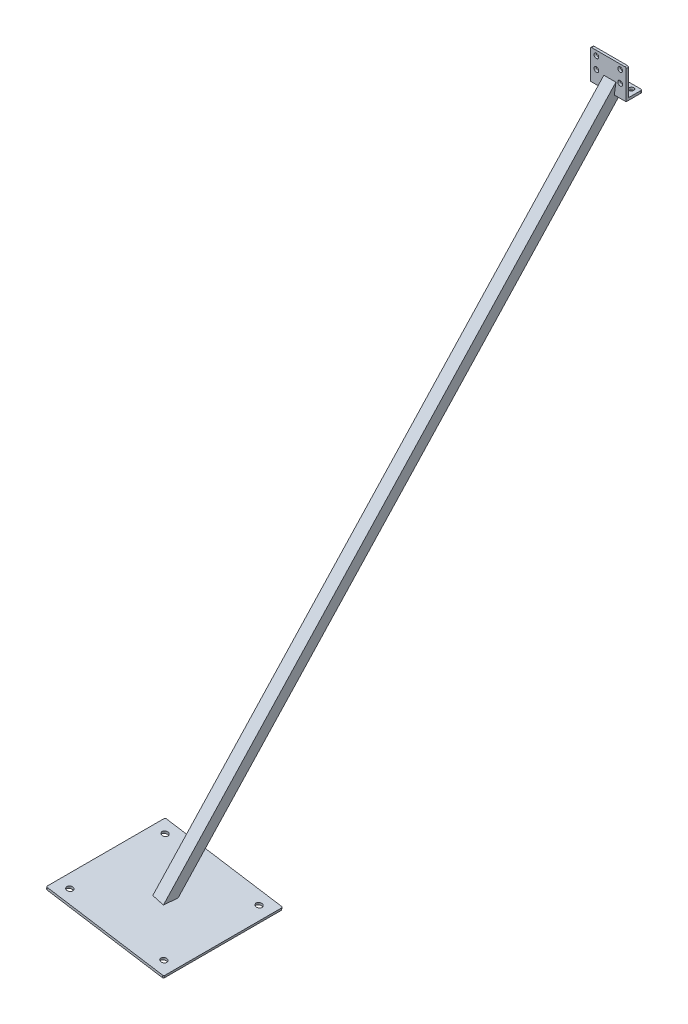
from build123d import *

# Parameters (mm, degrees)
BOSS_EXTRUDE1_DEPTH      = 60
SKETCH3_W                = 20
SKETCH3_H                = 20
SKETCH3_W_2              = 18
SKETCH3_H_2              = 18
BOSS_EXTRUDE2_DEPTH      = 2000
BOSS_EXTRUDE2_DEPTH_BACK = 20
CUT_EXTRUDE1_DEPTH       = 60
SKETCH6_W                = 200
SKETCH6_H                = 200
BOSS_EXTRUDE3_DEPTH      = 4
SKETCH7_W                = 155.890708873
SKETCH7_H                = 491.291930993
CUT_EXTRUDE2_DEPTH       = 1000
CUT_EXTRUDE3_REACH       = 29
SKETCH8_R                = 3.999999996
CUT_EXTRUDE4_REACH       = 52
SKETCH9_R                = 4.000000003
CUT_EXTRUDE5_REACH       = 1055.099
SKETCH10_R               = 5
FILLET1_R                = 2
FILLET2_R                = 2


with BuildPart() as part:
    # Sketch1 → Boss-Extrude1 (new body)
    with BuildSketch(Plane(origin=(0, 0, 0), x_dir=(0, 0, -1), z_dir=(1, 0, 0))):
        Polygon((0, 0), (0, 50), (4, 50), (4, 4), (27, 4), (27, 0), align=None)
    extrude(amount=BOSS_EXTRUDE1_DEPTH)

    # Sketch3 → Boss-Extrude2 (add, two sides)
    with BuildSketch(Plane(origin=(0.734152256, 4.01424851, -2.317627458), x_dir=(0, -0.5, -0.866025404), z_dir=(-0.156434465, -0.855363194, 0.49384417))) as boss_extrude2_sk:
        with Locations((0, 29.630650218)):
            Rectangle(SKETCH3_W, SKETCH3_H)
        with Locations((0, 29.630650218)):
            Rectangle(SKETCH3_W_2, SKETCH3_H_2, mode=Mode.SUBTRACT)
    extrude(amount=BOSS_EXTRUDE2_DEPTH)
    extrude(boss_extrude2_sk.sketch, amount=-BOSS_EXTRUDE2_DEPTH_BACK)

    # Sketch4 → Cut-Extrude1 (cut)
    with BuildSketch(Plane.ZY):
        Polygon((-4, 4), (-4, 34.425897354), (-31.384039134, 4), align=None)
    extrude(amount=-CUT_EXTRUDE1_DEPTH, mode=Mode.SUBTRACT)

    # Sketch6 → Boss-Extrude3 (add)
    with BuildSketch(Plane(origin=(-155.547262091, -982.086761679, 2e-09), x_dir=(0.987688341, -0.156434465, 0), z_dir=(0.156434465, 0.987688341, 0))):
        with Locations((5.477031179, -566.441418586)):
            Rectangle(SKETCH6_W, SKETCH6_H)
    extrude(amount=BOSS_EXTRUDE3_DEPTH)

    # Sketch7 → Cut-Extrude2 (cut)
    with BuildSketch(Plane(origin=(-155.547262091, -982.086761679, 2e-09), x_dir=(0.987688341, -0.156434465, 0), z_dir=(-0.156434465, -0.987688341, 0))):
        with Locations((-7.001123273, 786.089826429)):
            Rectangle(SKETCH7_W, SKETCH7_H)
    extrude(amount=CUT_EXTRUDE2_DEPTH, mode=Mode.SUBTRACT)

    # Sketch8 → Cut-Extrude3 (cut, up to next)
    with BuildSketch(Plane.XY, mode=Mode.PRIVATE) as cut_extrude3_sk1:
        with Locations((10, 22)):
            Circle(SKETCH8_R)
    cut_extrude3_tool1 = extrude(cut_extrude3_sk1.sketch, amount=-CUT_EXTRUDE3_REACH, mode=Mode.PRIVATE) & part.part
    add(cut_extrude3_tool1.solids().sort_by_distance((10, 22, 0))[0], mode=Mode.SUBTRACT)
    # Sketch8 → Cut-Extrude3 (cut, up to next)
    with BuildSketch(Plane.XY, mode=Mode.PRIVATE) as cut_extrude3_sk2:
        with Locations((50, 22)):
            Circle(SKETCH8_R)
    cut_extrude3_tool2 = extrude(cut_extrude3_sk2.sketch, amount=-CUT_EXTRUDE3_REACH, mode=Mode.PRIVATE) & part.part
    add(cut_extrude3_tool2.solids().sort_by_distance((50, 22, 0))[0], mode=Mode.SUBTRACT)
    # Sketch8 → Cut-Extrude3 (cut, up to next)
    with BuildSketch(Plane.XY, mode=Mode.PRIVATE) as cut_extrude3_sk3:
        with Locations((50, 42)):
            Circle(SKETCH8_R)
    cut_extrude3_tool3 = extrude(cut_extrude3_sk3.sketch, amount=-CUT_EXTRUDE3_REACH, mode=Mode.PRIVATE) & part.part
    add(cut_extrude3_tool3.solids().sort_by_distance((50, 42, 0))[0], mode=Mode.SUBTRACT)
    # Sketch8 → Cut-Extrude3 (cut, up to next)
    with BuildSketch(Plane.XY, mode=Mode.PRIVATE) as cut_extrude3_sk4:
        with Locations((10, 42)):
            Circle(SKETCH8_R)
    cut_extrude3_tool4 = extrude(cut_extrude3_sk4.sketch, amount=-CUT_EXTRUDE3_REACH, mode=Mode.PRIVATE) & part.part
    add(cut_extrude3_tool4.solids().sort_by_distance((10, 42, 0))[0], mode=Mode.SUBTRACT)

    # Sketch9 → Cut-Extrude4 (cut, up to next)
    with BuildSketch(Plane.XZ, mode=Mode.PRIVATE) as cut_extrude4_sk1:
        with Locations((50, -19)):
            Circle(SKETCH9_R)
    cut_extrude4_tool1 = extrude(cut_extrude4_sk1.sketch, amount=-CUT_EXTRUDE4_REACH, mode=Mode.PRIVATE) & part.part
    add(cut_extrude4_tool1.solids().sort_by_distance((50, 0, -19))[0], mode=Mode.SUBTRACT)
    # Sketch9 → Cut-Extrude4 (cut, up to next)
    with BuildSketch(Plane.XZ, mode=Mode.PRIVATE) as cut_extrude4_sk2:
        with Locations((10, -19)):
            Circle(SKETCH9_R)
    cut_extrude4_tool2 = extrude(cut_extrude4_sk2.sketch, amount=-CUT_EXTRUDE4_REACH, mode=Mode.PRIVATE) & part.part
    add(cut_extrude4_tool2.solids().sort_by_distance((10, 0, -19))[0], mode=Mode.SUBTRACT)

    # Sketch10 → Cut-Extrude5 (cut, up to next)
    with BuildSketch(Plane(origin=(-155.547262091, -982.086761679, 2e-09), x_dir=(0.987688341, -0.156434465, 0), z_dir=(-0.156434465, -0.987688341, 0)), mode=Mode.PRIVATE) as cut_extrude5_sk1:
        with Locations((-74.522968944, 646.441418561)):
            Circle(SKETCH10_R)
    cut_extrude5_tool1 = extrude(cut_extrude5_sk1.sketch, amount=-CUT_EXTRUDE5_REACH, mode=Mode.PRIVATE) & part.part
    add(cut_extrude5_tool1.solids().sort_by_distance((-229.152729, -970.428801, 646.441419))[0], mode=Mode.SUBTRACT)
    # Sketch10 → Cut-Extrude5 (cut, up to next)
    with BuildSketch(Plane(origin=(-155.547262091, -982.086761679, 2e-09), x_dir=(0.987688341, -0.156434465, 0), z_dir=(-0.156434465, -0.987688341, 0)), mode=Mode.PRIVATE) as cut_extrude5_sk2:
        with Locations((85.477031056, 646.441418561)):
            Circle(SKETCH10_R)
    cut_extrude5_tool2 = extrude(cut_extrude5_sk2.sketch, amount=-CUT_EXTRUDE5_REACH, mode=Mode.PRIVATE) & part.part
    add(cut_extrude5_tool2.solids().sort_by_distance((-71.122595, -995.458315, 646.441419))[0], mode=Mode.SUBTRACT)
    # Sketch10 → Cut-Extrude5 (cut, up to next)
    with BuildSketch(Plane(origin=(-155.547262091, -982.086761679, 2e-09), x_dir=(0.987688341, -0.156434465, 0), z_dir=(-0.156434465, -0.987688341, 0)), mode=Mode.PRIVATE) as cut_extrude5_sk3:
        with Locations((85.477031056, 486.441418561)):
            Circle(SKETCH10_R)
    cut_extrude5_tool3 = extrude(cut_extrude5_sk3.sketch, amount=-CUT_EXTRUDE5_REACH, mode=Mode.PRIVATE) & part.part
    add(cut_extrude5_tool3.solids().sort_by_distance((-71.122595, -995.458315, 486.441419))[0], mode=Mode.SUBTRACT)
    # Sketch10 → Cut-Extrude5 (cut, up to next)
    with BuildSketch(Plane(origin=(-155.547262091, -982.086761679, 2e-09), x_dir=(0.987688341, -0.156434465, 0), z_dir=(-0.156434465, -0.987688341, 0)), mode=Mode.PRIVATE) as cut_extrude5_sk4:
        with Locations((-74.522968944, 486.441418561)):
            Circle(SKETCH10_R)
    cut_extrude5_tool4 = extrude(cut_extrude5_sk4.sketch, amount=-CUT_EXTRUDE5_REACH, mode=Mode.PRIVATE) & part.part
    add(cut_extrude5_tool4.solids().sort_by_distance((-229.152729, -970.428801, 486.441419))[0], mode=Mode.SUBTRACT)

    # Fillet1
    fillet1_edges = [part.edges().sort_by_distance(p)[0] for p in [
        (-248.593627385, -965.324734936, 466.441418588),
        (-248.593627385, -965.324734936, 666.441418588),
        (-51.055959265, -996.611627943, 666.441418588),
        (-51.055959265, -996.611627943, 466.441418588),
    ]]
    fillet(fillet1_edges, radius=FILLET1_R)

    # Fillet2
    fillet2_edges = [part.edges().sort_by_distance(p)[0] for p in [
        (60, 50, -2),
        (0, 50, -2),
        (60, 2, -27),
        (0, 2, -27),
    ]]
    fillet(fillet2_edges, radius=FILLET2_R)


solid = part.part
